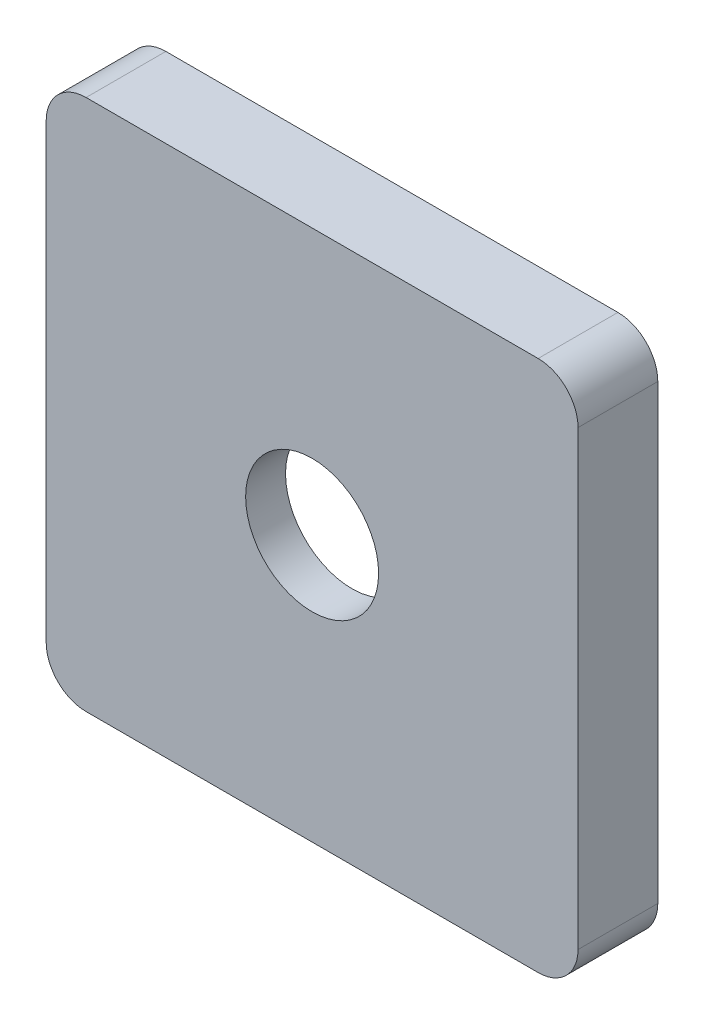
from build123d import *

# Parameters (mm, degrees)
SKETCH1_R           = 2.5
BOSS_EXTRUDE1_DEPTH = 1.5
SKETCH2_R           = 5
CUT_EXTRUDE1_DEPTH  = 1.5


with BuildPart() as part:
    # Sketch1 → Boss-Extrude1 (new body, symmetric)
    with BuildSketch(Plane.XY):
        with BuildLine():
            Line((-8.5, 10), (8.5, 10))
            ThreePointArc((8.5, 10), (9.560660172, 9.560660172), (10, 8.5))
            Line((10, 8.5), (10, -8.5))
            ThreePointArc((10, -8.5), (9.560660172, -9.560660172), (8.5, -10))
            Line((8.5, -10), (-8.5, -10))
            ThreePointArc((-8.5, -10), (-9.560660172, -9.560660172), (-10, -8.5))
            Line((-10, -8.5), (-10, 8.5))
            ThreePointArc((-10, 8.5), (-9.560660172, 9.560660172), (-8.5, 10))
        make_face()
        Circle(SKETCH1_R, mode=Mode.SUBTRACT)
    extrude(amount=BOSS_EXTRUDE1_DEPTH, both=True)

    # Sketch2 → Cut-Extrude1 (cut)
    with BuildSketch(Plane(origin=(0, 0, -1.5), x_dir=(-1, 0, 0), z_dir=(0, 0, -1))):
        Circle(SKETCH2_R)
    extrude(amount=-CUT_EXTRUDE1_DEPTH, mode=Mode.SUBTRACT)


solid = part.part
